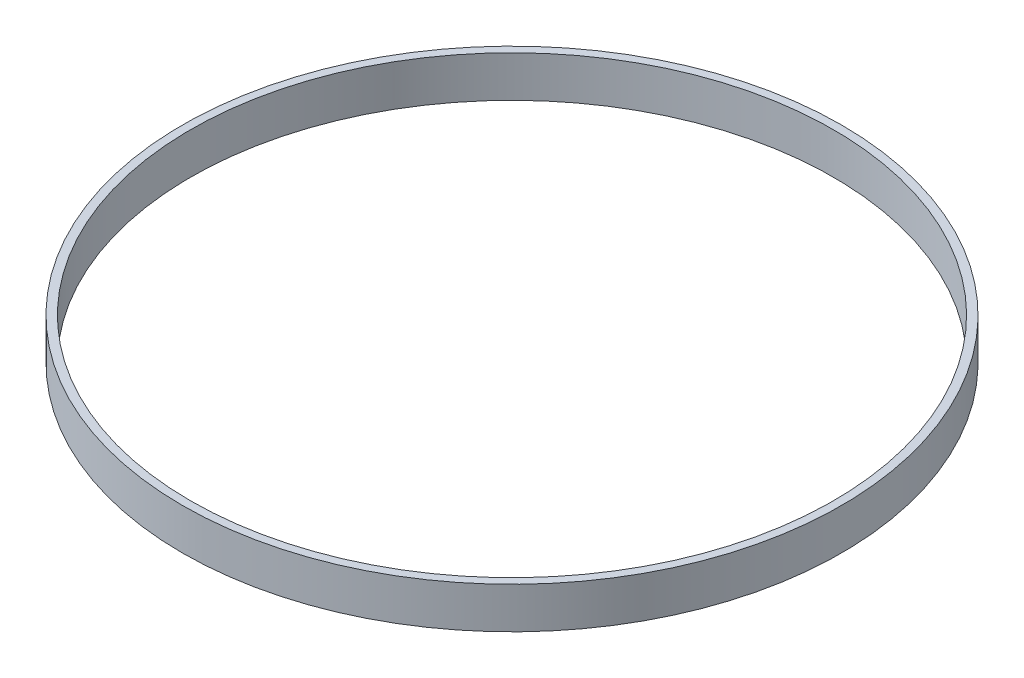
from build123d import *

# Parameters (mm, degrees)
SKETCH1_R           = 101.6
SKETCH1_R_2         = 99.1
BOSS_EXTRUDE1_DEPTH = 12.7


with BuildPart() as part:
    # Sketch1 → Boss-Extrude1 (new body)
    with BuildSketch(Plane(origin=(0, 0, 0), x_dir=(1, 0, 0), z_dir=(0, 1, 0))):
        Circle(SKETCH1_R)
        Circle(SKETCH1_R_2, mode=Mode.SUBTRACT)
    extrude(amount=BOSS_EXTRUDE1_DEPTH)


solid = part.part
